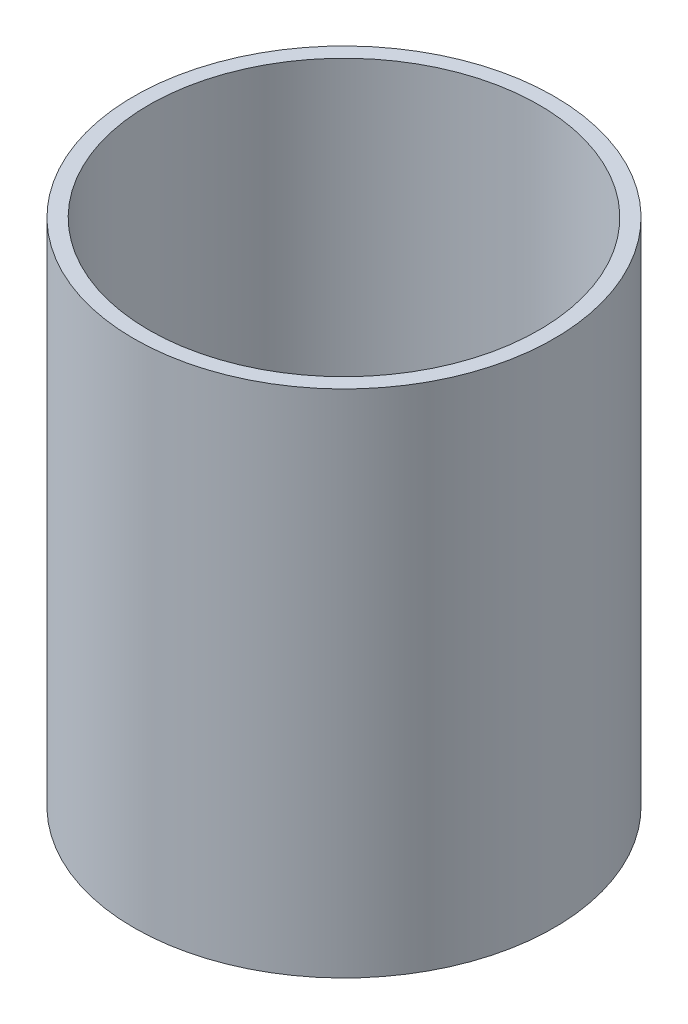
from build123d import *

# Parameters (mm, degrees)
SKETCH1_W = 3.175
SKETCH1_H = 107.95


with BuildPart() as part:
    # Sketch1 → Revolve1 (revolve)
    with BuildSketch(Plane.XY):
        with Locations((-42.8625, -16.995896605)):
            Rectangle(SKETCH1_W, SKETCH1_H)
    revolve(axis=Axis((0, 55, 0), (0, -1, 0)))


solid = part.part
